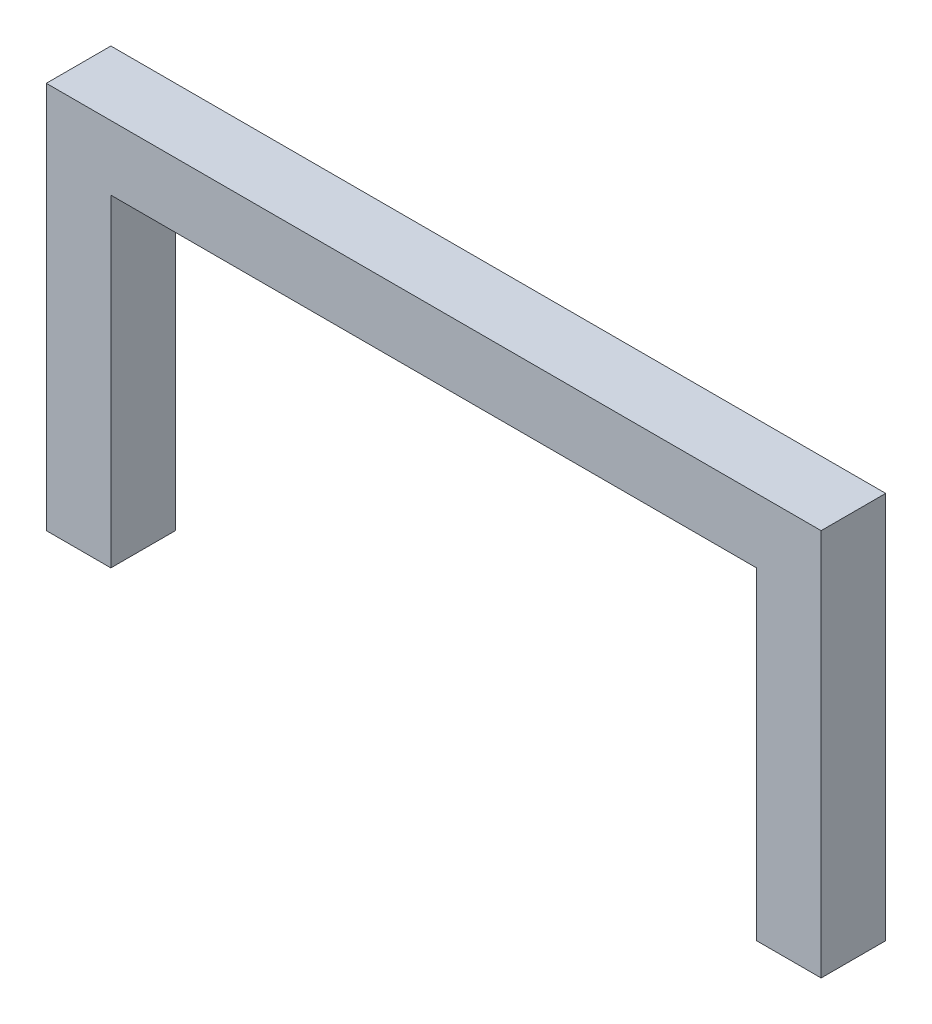
from build123d import *

# Parameters (mm, degrees)
BOSS_EXTRUDE1_DEPTH = 3.175


with BuildPart() as part:
    # Sketch1 → Boss-Extrude1 (new body)
    with BuildSketch(Plane.XY):
        Polygon((-3.175, 0), (-3.175, 19.05), (34.925, 19.05), (34.925, 0), (31.75, 0), (31.75, 15.875), (0, 15.875), (0, 0), align=None)
    extrude(amount=BOSS_EXTRUDE1_DEPTH)


solid = part.part
